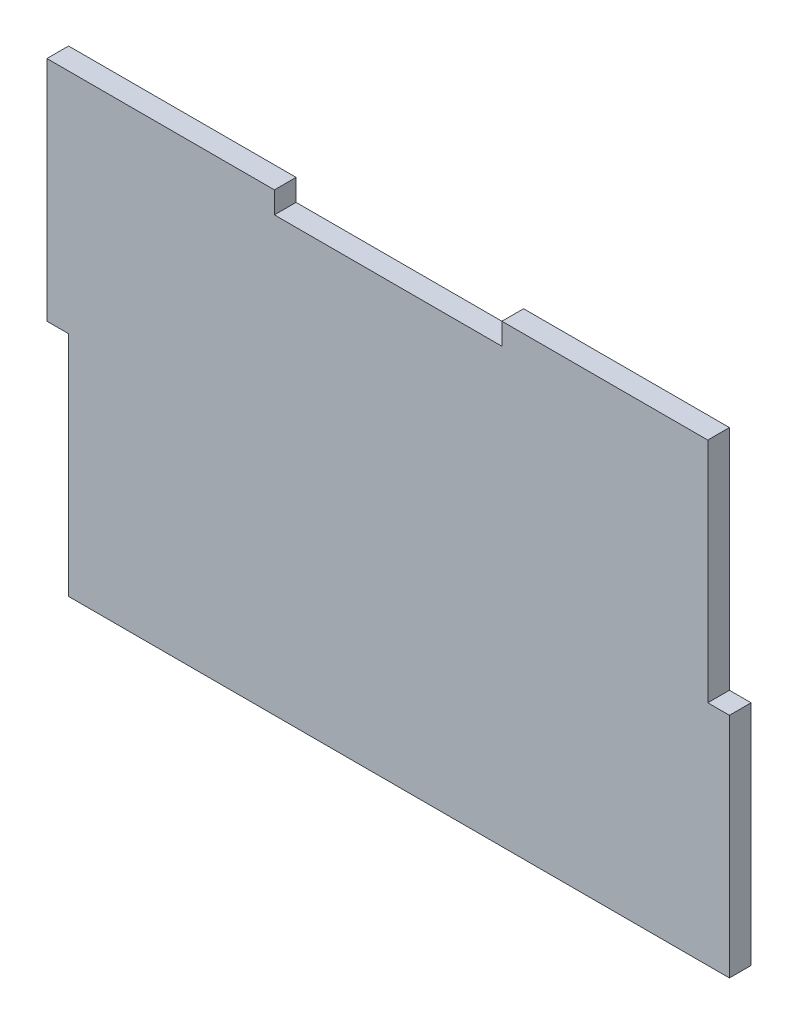
from build123d import *

# Parameters (mm, degrees)
BOSS_EXTRUDE1_DEPTH = 3.175


with BuildPart() as part:
    # Sketch1 → Boss-Extrude1 (new body)
    with BuildSketch(Plane.XY):
        Polygon((-50, 16.666666667), (-50, 50), (-16.666666667, 50), (-16.666666667, 46.825), (16.666666667, 46.825), (16.666666667, 50), (46.825, 50), (46.825, 16.666666667), (50, 16.666666667), (50, -16.666666667), (46.825, -16.666666667), (-46.825, -16.666666667), (-46.825, 16.666666667), align=None)
    extrude(amount=BOSS_EXTRUDE1_DEPTH)


solid = part.part
